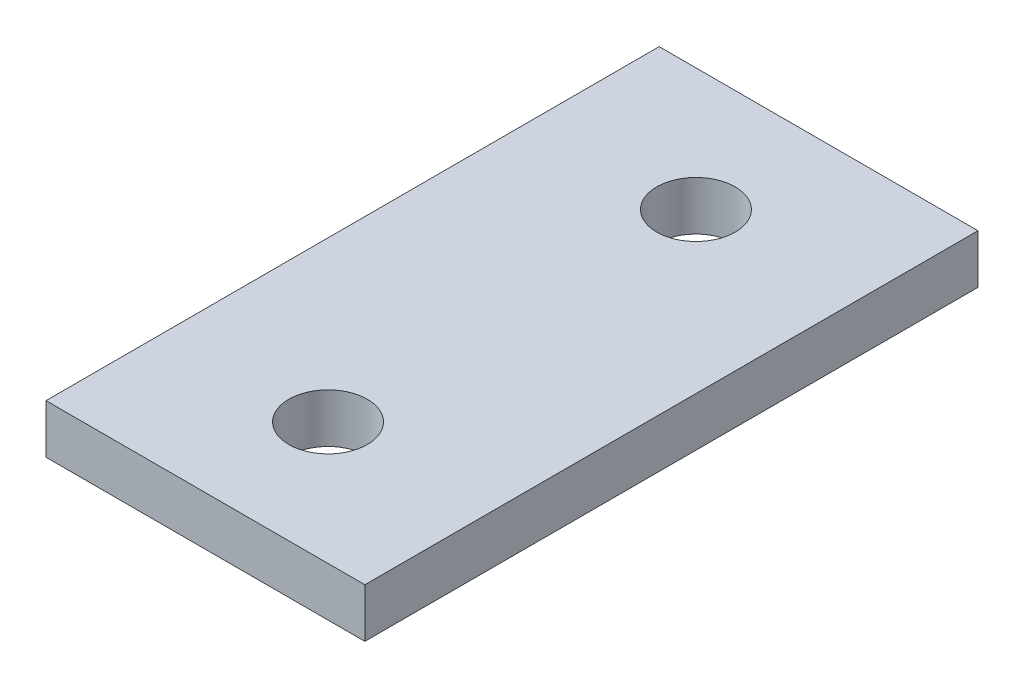
from build123d import *

# Parameters (mm, degrees)
SKETCH1_W           = 13
SKETCH1_H           = 25
SKETCH1_R           = 1.6
BOSS_EXTRUDE1_DEPTH = 2


with BuildPart() as part:
    # Sketch1 → Boss-Extrude1 (new body)
    with BuildSketch(Plane(origin=(0, 0, 0), x_dir=(1, 0, 0), z_dir=(0, 1, 0))):
        Rectangle(SKETCH1_W, SKETCH1_H)
        with Locations((0, 7.5)):
            Circle(SKETCH1_R, mode=Mode.SUBTRACT)
        with Locations((0, -7.5)):
            Circle(SKETCH1_R, mode=Mode.SUBTRACT)
    extrude(amount=BOSS_EXTRUDE1_DEPTH)


solid = part.part
